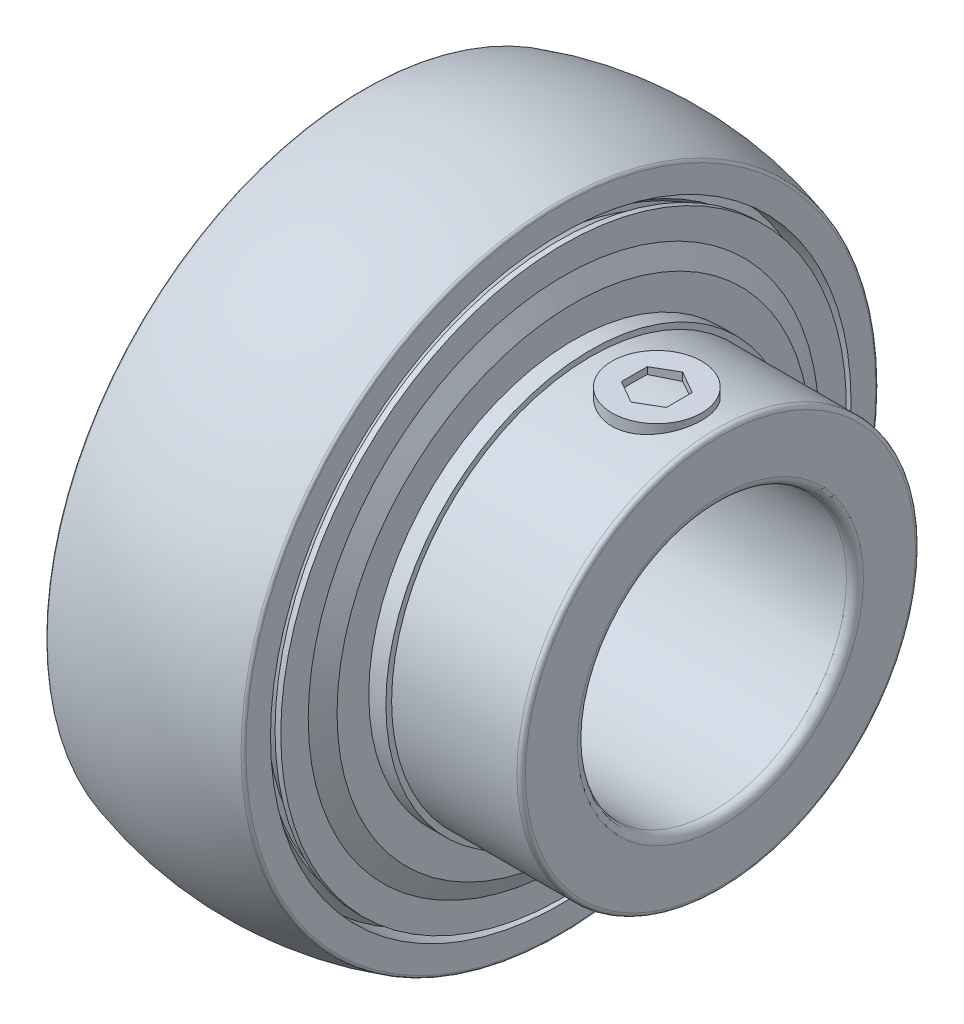
from build123d import *

# Parameters (mm, degrees)
CROQUIS2_R              = 3.175
SALIENTE_EXTRUIR1_DEPTH = 5.0325
CROQUIS3_R              = 3.175
SALIENTE_EXTRUIR2_DEPTH = 5.0325


with BuildPart() as part:
    # Croquis1 → Revolución1 (revolve)
    with BuildSketch(Plane.XY):
        with BuildLine():
            Line((-12.7, 13.8), (-12.7, 10.125))
            ThreePointArc((-12.7, 10.125), (-12.524264069, 9.700735931), (-12.1, 9.525))
            Line((-12.1, 9.525), (17.7, 9.525))
            ThreePointArc((17.7, 9.525), (18.124264069, 9.700735931), (18.3, 10.125))
            Line((18.3, 10.125), (18.3, 13.8))
            ThreePointArc((18.3, 13.8), (18.212132034, 14.012132034), (18, 14.1))
            Line((18, 14.1), (2.954735352, 14.1))
            ThreePointArc((2.954735352, 14.1), (0, 12.781), (-2.954735352, 14.1))
            Line((-2.954735352, 14.1), (-12.4, 14.1))
            ThreePointArc((-12.4, 14.1), (-12.612132034, 14.012132034), (-12.7, 13.8))
        make_face()
    revolve(axis=Axis((50, 0, 0), (-1, 0, 0)))

    # Croquis2 → Saliente-Extruir1 (add)
    with BuildSketch(Plane(origin=(0, 9.525, 0), x_dir=(1, 0, 0), z_dir=(0, 1, 0))):
        with Locations((13.8, 0)):
            Circle(CROQUIS2_R)
        Polygon((12.2125, -0.916543552), (13.8, -1.833087105), (15.3875, -0.916543552), (15.3875, 0.916543552), (13.8, 1.833087105), (12.2125, 0.916543552), align=None, mode=Mode.SUBTRACT)
    extrude(amount=SALIENTE_EXTRUIR1_DEPTH)

    # Croquis3 → Saliente-Extruir2 (add)
    with BuildSketch(Plane(origin=(0, -4.7625, -8.248891971), x_dir=(-1, 0, 0), z_dir=(0, -0.5, -0.866025404))):
        with Locations((-13.8, 0)):
            Circle(CROQUIS3_R)
        Polygon((-12.2125, 0.916543552), (-13.8, 1.833087105), (-15.3875, 0.916543552), (-15.3875, -0.916543552), (-13.8, -1.833087105), (-12.2125, -0.916543552), align=None, mode=Mode.SUBTRACT)
    extrude(amount=SALIENTE_EXTRUIR2_DEPTH)

    # Croquis4 → Revolución2 (revolve)
    with BuildSketch(Plane.XY):
        with BuildLine():
            Line((4.575202, 20.584289), (4.575202, 18.0714))
            Line((4.575202, 18.0714), (5.114046, 17.4095))
            Line((5.114046, 17.4095), (5.114046, 16.0857))
            Line((5.114046, 16.0857), (4.575202, 15.4238))
            Line((4.575202, 15.4238), (4.575202, 14.7619))
            Line((4.575202, 14.7619), (4.709913, 14.1))
            Line((4.709913, 14.1), (5.114046, 14.1))
            Line((5.114046, 14.1), (4.9928061, 14.69571))
            Line((4.9928061, 14.69571), (6.1109074, 14.69571))
            Line((6.1109074, 14.69571), (6.1109074, 17.450031687))
            Line((6.1109074, 17.450031687), (4.87296462, 18.294533561))
            Line((4.87296462, 18.294533561), (4.918513787, 18.36130341))
            Line((4.918513787, 18.36130341), (6.191734, 17.492735917))
            Line((6.191734, 17.492735917), (6.191734, 14.49714))
            Line((6.191734, 14.49714), (6.595867, 14.49714))
            Line((6.595867, 14.49714), (6.595867, 17.706257068))
            Line((6.595867, 17.706257068), (7.288629669, 16.984571675))
            ThreePointArc((7.288629669, 16.984571675), (7.455397796, 16.726505345), (7.5138005, 16.424845))
            Line((7.5138005, 16.424845), (7.5138005, 14.1))
            Line((7.5138005, 14.1), (9.1303325, 14.1))
            Line((9.1303325, 14.1), (9.1303325, 14.504133))
            Line((9.1303325, 14.504133), (7.9179335, 14.504133))
            Line((7.9179335, 14.504133), (7.9179335, 16.75))
            Line((7.9179335, 16.75), (7.2020665, 18.073))
            Line((7.2020665, 18.073), (7.2020665, 20.0169335))
            Line((7.2020665, 20.0169335), (6.7979335, 20.0169335))
            Line((6.7979335, 20.0169335), (6.7979335, 18.073))
            Line((6.7979335, 18.073), (5.748108549, 18.284582344))
            Line((5.748108549, 18.284582344), (4.979335, 18.809025569))
            Line((4.979335, 18.809025569), (4.979335, 19.955569663))
            Line((4.979335, 19.955569663), (5.383468, 19.473942708))
            Line((5.383468, 19.473942708), (5.693051839, 19.733714393))
            Line((5.693051839, 19.733714393), (4.979335, 20.584289))
            ThreePointArc((4.979335, 20.584289), (4.939879062, 20.679544062), (4.844624, 20.719))
            Line((4.844624, 20.719), (4.709913, 20.719))
            ThreePointArc((4.709913, 20.719), (4.614657938, 20.679544062), (4.575202, 20.584289))
        make_face()
    revolve(axis=Axis((7, 0, 0), (-1, 0, 0)))

    # Croquis5 → Revolución3 (revolve)
    with BuildSketch(Plane.XY):
        with BuildLine():
            Line((-7, 20.5419335), (-5.0616905, 20.5419335))
            Line((-5.0616905, 20.5419335), (-4.913176277, 20.661187574))
            ThreePointArc((-4.913176277, 20.661187574), (-4.701999271, 20.695532146), (-4.563946754, 20.532079461))
            Line((-4.563946754, 20.532079461), (-4.488696052, 20.132223271))
            ThreePointArc((-4.488696052, 20.132223271), (-4.401225913, 19.983690295), (-4.23907797, 19.9252))
            Line((-4.23907797, 19.9252), (-2.464612822, 19.9252))
            ThreePointArc((-2.464612822, 19.9252), (-2.386743978, 19.937430599), (-2.31637421, 19.972944542))
            ThreePointArc((-2.31637421, 19.972944542), (0, 20.719), (2.31637421, 19.972944542))
            ThreePointArc((2.31637421, 19.972944542), (2.386743978, 19.937430599), (2.464612822, 19.9252))
            Line((2.464612822, 19.9252), (4.23907797, 19.9252))
            ThreePointArc((4.23907797, 19.9252), (4.401225913, 19.983690295), (4.488696052, 20.132223271))
            Line((4.488696052, 20.132223271), (4.563946754, 20.532079461))
            ThreePointArc((4.563946754, 20.532079461), (4.701999271, 20.695532146), (4.913176277, 20.661187574))
            Line((4.913176277, 20.661187574), (5.0616905, 20.5419335))
            Line((5.0616905, 20.5419335), (7, 20.5419335))
            Line((7, 20.5419335), (7, 22.285645604))
            ThreePointArc((7, 22.285645604), (6.960738638, 22.404654386), (6.858369099, 22.4769387))
            ThreePointArc((6.858369099, 22.4769387), (0, 23.5), (-6.858369099, 22.4769387))
            ThreePointArc((-6.858369099, 22.4769387), (-6.960738638, 22.404654386), (-7, 22.285645604))
            Line((-7, 22.285645604), (-7, 20.5419335))
        make_face()
    revolve(axis=Axis((7, 0, 0), (-1, 0, 0)))

    # Croquis6 → Revolución4 (revolve)
    with BuildSketch(Plane.XY):
        with BuildLine():
            Line((-9.1303325, 14.504133), (-9.1303325, 14.1))
            Line((-9.1303325, 14.1), (-7.5138005, 14.1))
            Line((-7.5138005, 14.1), (-7.5138005, 16.424845))
            ThreePointArc((-7.5138005, 16.424845), (-7.455397796, 16.726505345), (-7.288629669, 16.984571675))
            Line((-7.288629669, 16.984571675), (-6.595867, 17.706257068))
            Line((-6.595867, 17.706257068), (-6.595867, 14.49714))
            Line((-6.595867, 14.49714), (-6.191734, 14.49714))
            Line((-6.191734, 14.49714), (-6.191734, 17.492735917))
            Line((-6.191734, 17.492735917), (-4.918513787, 18.36130341))
            Line((-4.918513787, 18.36130341), (-4.87296462, 18.294533561))
            Line((-4.87296462, 18.294533561), (-6.1109074, 17.450031687))
            Line((-6.1109074, 17.450031687), (-6.1109074, 14.69571))
            Line((-6.1109074, 14.69571), (-4.9928061, 14.69571))
            Line((-4.9928061, 14.69571), (-5.114046, 14.1))
            Line((-5.114046, 14.1), (-4.709913, 14.1))
            Line((-4.709913, 14.1), (-4.575202, 14.7619))
            Line((-4.575202, 14.7619), (-4.575202, 15.4238))
            Line((-4.575202, 15.4238), (-5.114046, 16.0857))
            Line((-5.114046, 16.0857), (-5.114046, 17.4095))
            Line((-5.114046, 17.4095), (-4.575202, 18.0714))
            Line((-4.575202, 18.0714), (-4.575202, 20.584289))
            ThreePointArc((-4.575202, 20.584289), (-4.614657938, 20.679544062), (-4.709913, 20.719))
            Line((-4.709913, 20.719), (-4.844624, 20.719))
            ThreePointArc((-4.844624, 20.719), (-4.939879062, 20.679544062), (-4.979335, 20.584289))
            Line((-4.979335, 20.584289), (-5.693051839, 19.733714393))
            Line((-5.693051839, 19.733714393), (-5.383468, 19.473942708))
            Line((-5.383468, 19.473942708), (-4.979335, 19.955569663))
            Line((-4.979335, 19.955569663), (-4.979335, 18.809025569))
            Line((-4.979335, 18.809025569), (-5.748108549, 18.284582344))
            Line((-5.748108549, 18.284582344), (-6.7979335, 18.073))
            Line((-6.7979335, 18.073), (-6.7979335, 20.0169335))
            Line((-6.7979335, 20.0169335), (-7.2020665, 20.0169335))
            Line((-7.2020665, 20.0169335), (-7.2020665, 18.073))
            Line((-7.2020665, 18.073), (-7.9179335, 16.75))
            Line((-7.9179335, 16.75), (-7.9179335, 14.504133))
            Line((-7.9179335, 14.504133), (-9.1303325, 14.504133))
        make_face()
    revolve(axis=Axis((7, 0, 0), (-1, 0, 0)))


solid = part.part
